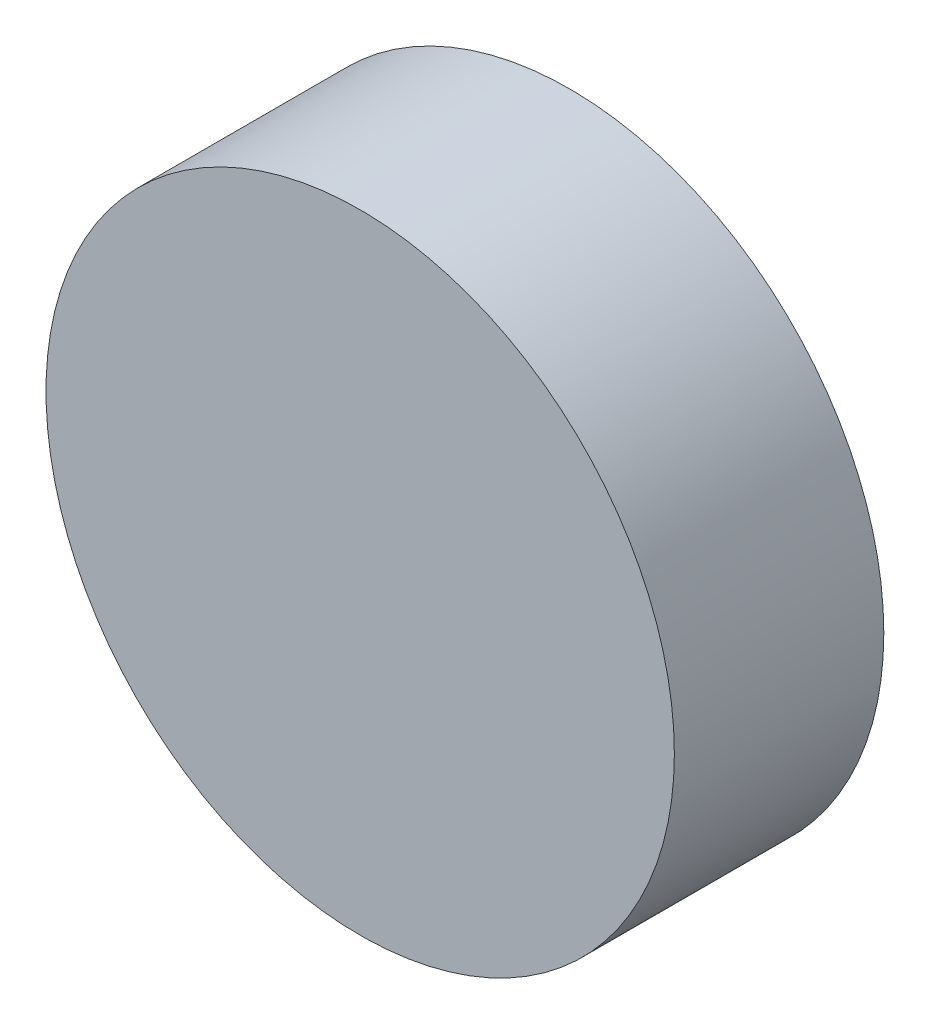
from build123d import *

# Parameters (mm, degrees)
MAINSKETCH_R = 38.1
MAIN_DEPTH   = 25.4


with BuildPart() as part:
    # MainSketch → Main (new body)
    with BuildSketch(Plane.XY):
        Circle(MAINSKETCH_R)
    extrude(amount=MAIN_DEPTH)


solid = part.part
